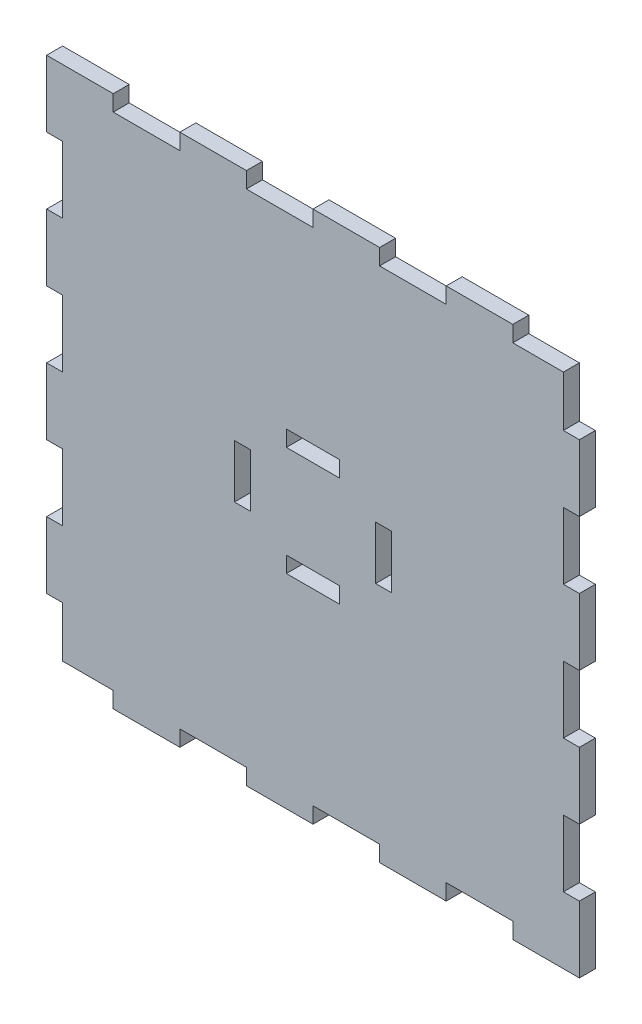
from build123d import *

# Parameters (mm, degrees)
ESBO_O1_W                = 6
ESBO_O1_H                = 20
RESSALTO_EXTRUS_O1_DEPTH = 6


with BuildPart() as part:
    # Esboço1 → Ressalto-extrusão1 (new body)
    with BuildSketch(Plane.XY):
        Polygon((194, 150), (200, 150), (200, 175), (194, 175), (194, 194), (175, 194), (175, 200), (150, 200), (150, 194), (125, 194), (125, 200), (100, 200), (100, 194), (75, 194), (75, 200), (50, 200), (50, 194), (25, 194), (25, 200), (0, 200), (0, 175), (6, 175), (6, 150), (0, 150), (0, 125), (6, 125), (6, 100), (0, 100), (0, 75), (6, 75), (6, 50), (0, 50), (0, 25), (6, 25), (6, 6), (25, 6), (25, 0), (50, 0), (50, 6), (75, 6), (75, 0), (100, 0), (100, 6), (125, 6), (125, 0), (150, 0), (150, 6), (175, 6), (175, 0), (200, 0), (200, 25), (194, 25), (194, 50), (200, 50), (200, 75), (194, 75), (194, 100), (200, 100), (200, 125), (194, 125), align=None)
        Polygon((100, 76.5), (90, 76.5), (90, 82.5), (100, 82.5), (110, 82.5), (110, 76.5), align=None, mode=Mode.SUBTRACT)
        with Locations((73.5, 100)):
            Rectangle(ESBO_O1_W, ESBO_O1_H, mode=Mode.SUBTRACT)
        Polygon((110, 117.5), (100, 117.5), (90, 117.5), (90, 123.5), (100, 123.5), (110, 123.5), align=None, mode=Mode.SUBTRACT)
        with Locations((126.5, 100)):
            Rectangle(ESBO_O1_W, ESBO_O1_H, mode=Mode.SUBTRACT)
    extrude(amount=RESSALTO_EXTRUS_O1_DEPTH)


solid = part.part
